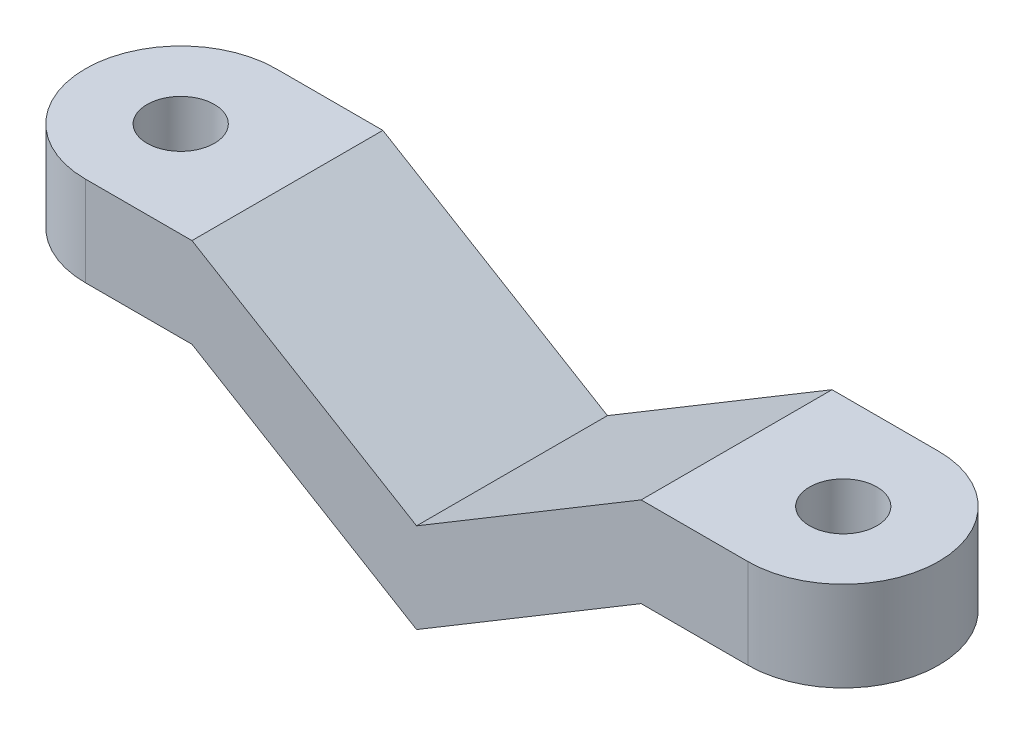
from build123d import *

# Parameters (mm, degrees)
BOSS_EXTRUDE1_DEPTH = 10
SKETCH3_W           = 4.25
SKETCH3_H           = 6
CUT_EXTRUDE1_DEPTH  = 10
SKETCH4_R           = 1.5
CUT_EXTRUDE2_DEPTH  = 11


with BuildPart() as part:
    # Sketch2 → Boss-Extrude1 (new body)
    with BuildSketch(Plane(origin=(0, 0, 0), x_dir=(1, 0, 0), z_dir=(0, 1, 0))):
        with BuildLine():
            Line((0, -4.25), (29.5, -4.25))
            ThreePointArc((29.5, -4.25), (33.75, 0), (29.5, 4.25))
            Line((29.5, 4.25), (0, 4.25))
            ThreePointArc((0, 4.25), (-4.25, 0), (0, -4.25))
        make_face()
    extrude(amount=BOSS_EXTRUDE1_DEPTH)

    # Sketch3 → Cut-Extrude1 (cut)
    with BuildSketch(Plane.XY.offset(4.25)):
        Polygon((24.75, 10), (4.75, 10), (14.75, 4), align=None)
        Polygon((4.75, 6), (0, 6), (0, 0), (14.75, 0), align=None)
        with Locations((-2.125, 3)):
            Rectangle(SKETCH3_W, SKETCH3_H)
        Polygon((29.5, 0), (29.5, 6), (24.75, 6), (14.75, 0), align=None)
        with Locations((31.625, 3)):
            Rectangle(SKETCH3_W, SKETCH3_H)
    extrude(amount=-CUT_EXTRUDE1_DEPTH, mode=Mode.SUBTRACT)

    # Sketch4 → Cut-Extrude2 (cut, through all)
    with BuildSketch(Plane(origin=(0, 10, 0), x_dir=(1, 0, 0), z_dir=(0, 1, 0))):
        Circle(SKETCH4_R)
        with Locations((29.5, 0)):
            Circle(SKETCH4_R)
    extrude(amount=-CUT_EXTRUDE2_DEPTH, mode=Mode.SUBTRACT)


solid = part.part
